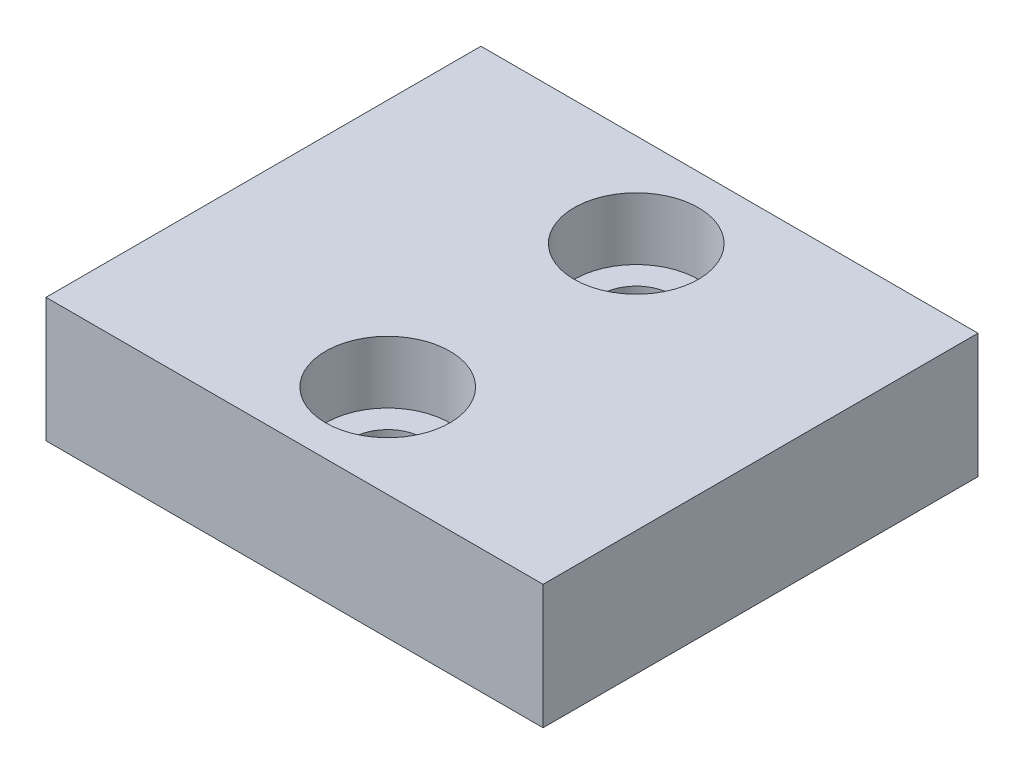
from build123d import *

# Parameters (mm, degrees)
SKETCH_1_W          = 16
SKETCH_1_H          = 14
SKETCH_1_R          = 1.15
EXTRUDE_1_DEPTH     = 4
SKETCH_2_R          = 2
CUT_EXTRUDE_1_DEPTH = 2


with BuildPart() as part:
    # 스케치1 → 보스-돌출1 (new body)
    with BuildSketch(Plane(origin=(0, 0, 0), x_dir=(1, 0, 0), z_dir=(0, 1, 0))):
        Rectangle(SKETCH_1_W, SKETCH_1_H)
        with Locations((0, 4)):
            Circle(SKETCH_1_R, mode=Mode.SUBTRACT)
        with Locations((0, -4)):
            Circle(SKETCH_1_R, mode=Mode.SUBTRACT)
    extrude(amount=EXTRUDE_1_DEPTH)

    # 스케치2 → 컷-돌출1 (cut)
    with BuildSketch(Plane(origin=(0, 4, 0), x_dir=(1, 0, 0), z_dir=(0, 1, 0))):
        with Locations((0, 4)):
            Circle(SKETCH_2_R)
        with Locations((0, -4)):
            Circle(SKETCH_2_R)
    extrude(amount=-CUT_EXTRUDE_1_DEPTH, mode=Mode.SUBTRACT)


solid = part.part
